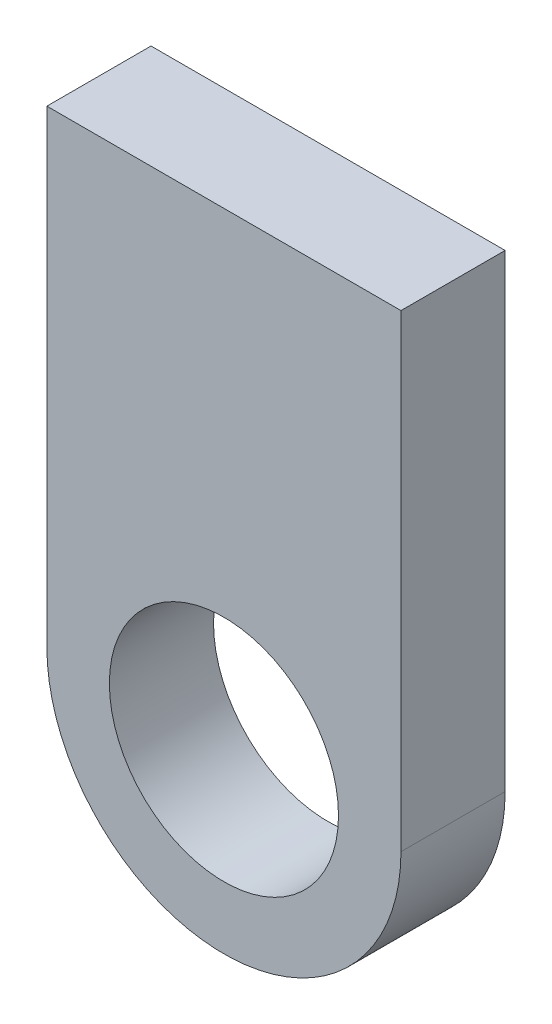
from build123d import *

# Parameters (mm, degrees)
SKETCH2_R           = 0.55
BOSS_EXTRUDE1_DEPTH = 0.5


with BuildPart() as part:
    # Sketch2 → Boss-Extrude1 (new body)
    with BuildSketch(Plane.XY):
        with BuildLine():
            Line((-0.85, 2.25), (0.85, 2.25))
            Line((0.85, 2.25), (0.85, 0))
            ThreePointArc((0.85, 0), (0, -0.85), (-0.85, 0))
            Line((-0.85, 0), (-0.85, 2.25))
        make_face()
        Circle(SKETCH2_R, mode=Mode.SUBTRACT)
    extrude(amount=BOSS_EXTRUDE1_DEPTH)


solid = part.part
